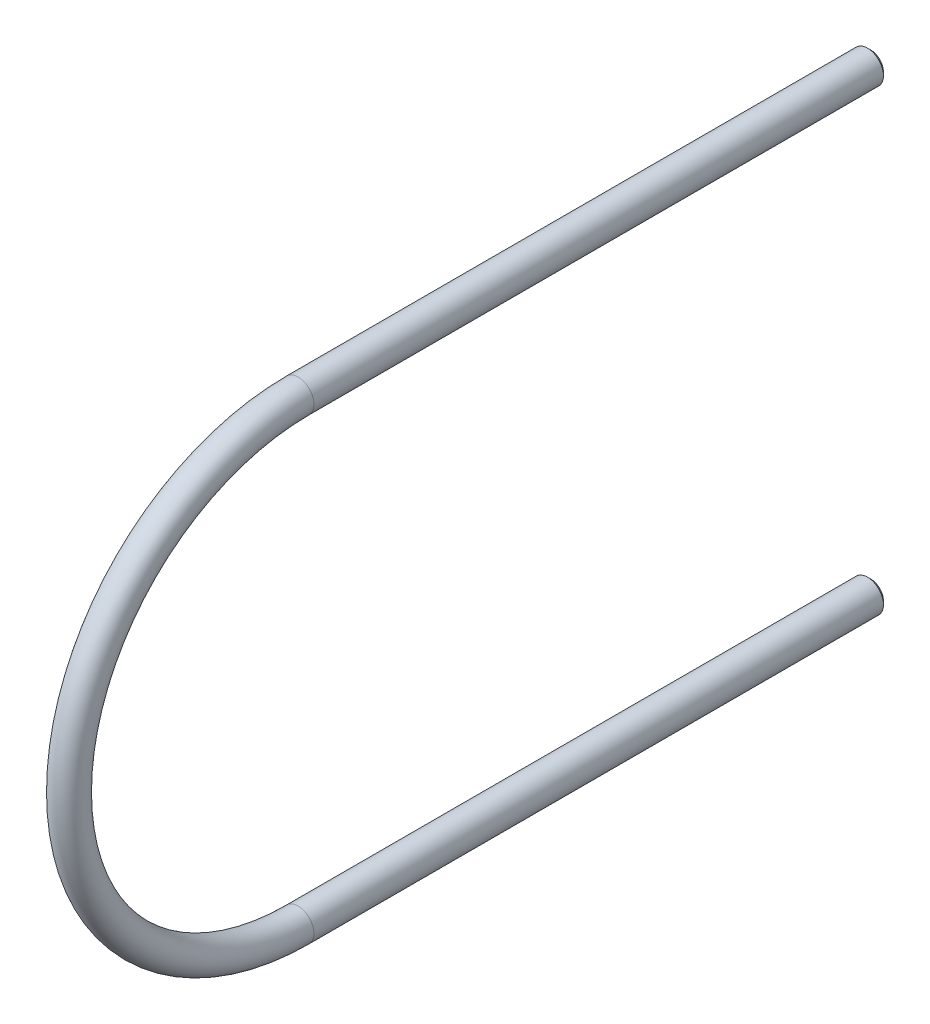
from build123d import *

# Parameters (mm, degrees)
SKETCH1_R           = 2.5
REVOLVE1_ANGLE      = 180
SKETCH1_2_R         = 2.5
BOSS_EXTRUDE1_DEPTH = 90
SKETCH2_R           = 2.5
BOSS_EXTRUDE2_DEPTH = 90
CHAMFER1_SIZE       = 0.5


with BuildPart() as part:
    # Sketch1 → Revolve1 (revolve)
    with BuildSketch(Plane.XY):
        with Locations((0, 36)):
            Circle(SKETCH1_R)
    revolve(axis=Axis((0, 0, 0), (1, 0, 0)), revolution_arc=REVOLVE1_ANGLE)

    # Sketch1_2 → Boss-Extrude1 (add)
    with BuildSketch(Plane.XY):
        with Locations((0, 36)):
            Circle(SKETCH1_2_R)
    extrude(amount=-BOSS_EXTRUDE1_DEPTH)

    # Sketch2 → Boss-Extrude2 (add)
    with BuildSketch(Plane(origin=(0, 0, 0), x_dir=(-1, 0, 0), z_dir=(0, 0, -1))):
        with Locations((0, -36)):
            Circle(SKETCH2_R)
    extrude(amount=BOSS_EXTRUDE2_DEPTH)

    # Chamfer1
    chamfer1_edges = [part.edges().sort_by_distance(p)[0] for p in [
        (2.5, -36, -90),
        (-2.5, 36, -90),
    ]]
    chamfer(chamfer1_edges, length=CHAMFER1_SIZE)


solid = part.part
